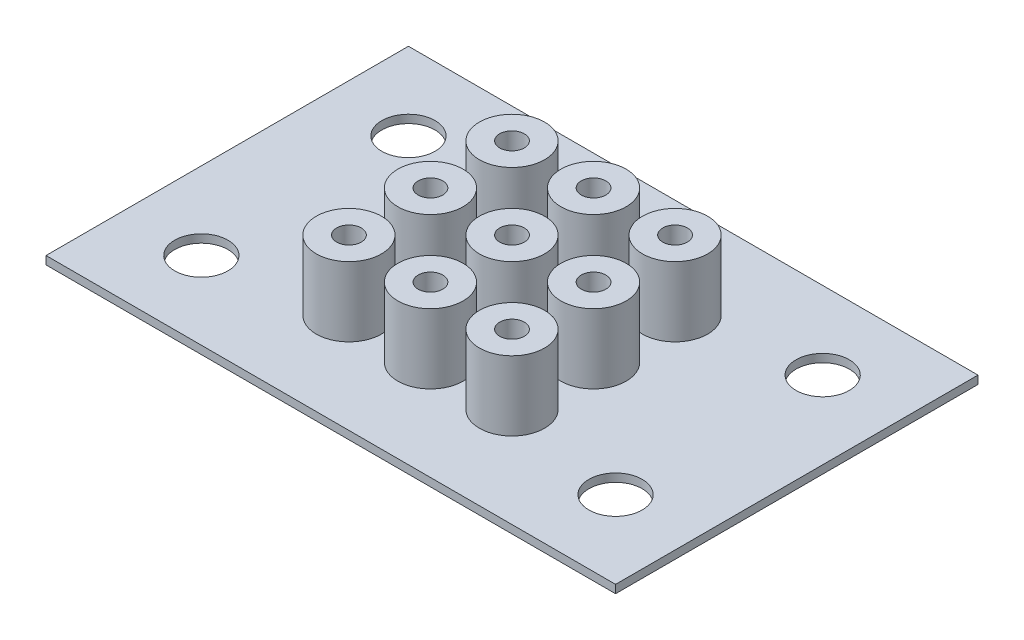
from build123d import *

# Parameters (mm, degrees)
SKETCH1_W           = 69.85
SKETCH1_H           = 44.45
SKETCH1_R           = 1.25
SKETCH1_R_2         = 3.2639
BOSS_EXTRUDE1_DEPTH = 1
SKETCH2_R           = 4
SKETCH2_R_2         = 1.51
BOSS_EXTRUDE2_DEPTH = 8.525


with BuildPart() as part:
    # Sketch1 → Boss-Extrude1 (new body)
    with BuildSketch(Plane(origin=(0, 0, 0), x_dir=(1, 0, 0), z_dir=(0, 1, 0))):
        with Locations((34.925, 22.225)):
            Rectangle(SKETCH1_W, SKETCH1_H)
        with Locations((24.925, 12.225)):
            Circle(SKETCH1_R, mode=Mode.SUBTRACT)
        with Locations((34.925, 12.225)):
            Circle(SKETCH1_R, mode=Mode.SUBTRACT)
        with Locations((44.925, 12.225)):
            Circle(SKETCH1_R, mode=Mode.SUBTRACT)
        with Locations((24.925, 32.225)):
            Circle(SKETCH1_R, mode=Mode.SUBTRACT)
        with Locations((24.925, 22.225)):
            Circle(SKETCH1_R, mode=Mode.SUBTRACT)
        with Locations((34.925, 32.225)):
            Circle(SKETCH1_R, mode=Mode.SUBTRACT)
        with Locations((44.925, 32.225)):
            Circle(SKETCH1_R, mode=Mode.SUBTRACT)
        with Locations((44.925, 22.225)):
            Circle(SKETCH1_R, mode=Mode.SUBTRACT)
        with Locations((34.925, 22.225)):
            Circle(SKETCH1_R, mode=Mode.SUBTRACT)
        with Locations((60.325, 9.525)):
            Circle(SKETCH1_R_2, mode=Mode.SUBTRACT)
        with Locations((9.525, 9.525)):
            Circle(SKETCH1_R_2, mode=Mode.SUBTRACT)
        with Locations((60.325, 34.925)):
            Circle(SKETCH1_R_2, mode=Mode.SUBTRACT)
        with Locations((9.525, 34.925)):
            Circle(SKETCH1_R_2, mode=Mode.SUBTRACT)
    extrude(amount=BOSS_EXTRUDE1_DEPTH)

    # Sketch2 → Boss-Extrude2 (add)
    with BuildSketch(Plane(origin=(0, 1, 0), x_dir=(1, 0, 0), z_dir=(0, 1, 0))):
        with Locations((34.925, 22.225)):
            Circle(SKETCH2_R)
        with Locations((34.925, 22.225)):
            Circle(SKETCH2_R_2, mode=Mode.SUBTRACT)
        with Locations((44.925, 22.225)):
            Circle(SKETCH2_R)
        with Locations((44.925, 22.225)):
            Circle(SKETCH2_R_2, mode=Mode.SUBTRACT)
        with Locations((44.925, 32.225)):
            Circle(SKETCH2_R)
        with Locations((44.925, 32.225)):
            Circle(SKETCH2_R_2, mode=Mode.SUBTRACT)
        with Locations((34.925, 32.225)):
            Circle(SKETCH2_R)
        with Locations((34.925, 32.225)):
            Circle(SKETCH2_R_2, mode=Mode.SUBTRACT)
        with Locations((44.925, 12.225)):
            Circle(SKETCH2_R)
        with Locations((44.925, 12.225)):
            Circle(SKETCH2_R_2, mode=Mode.SUBTRACT)
        with Locations((34.925, 12.225)):
            Circle(SKETCH2_R)
        with Locations((34.925, 12.225)):
            Circle(SKETCH2_R_2, mode=Mode.SUBTRACT)
        with Locations((24.925, 22.225)):
            Circle(SKETCH2_R)
        with Locations((24.925, 22.225)):
            Circle(SKETCH2_R_2, mode=Mode.SUBTRACT)
        with Locations((24.925, 32.225)):
            Circle(SKETCH2_R)
        with Locations((24.925, 32.225)):
            Circle(SKETCH2_R_2, mode=Mode.SUBTRACT)
        with Locations((24.925, 12.225)):
            Circle(SKETCH2_R)
        with Locations((24.925, 12.225)):
            Circle(SKETCH2_R_2, mode=Mode.SUBTRACT)
    extrude(amount=BOSS_EXTRUDE2_DEPTH)


solid = part.part
